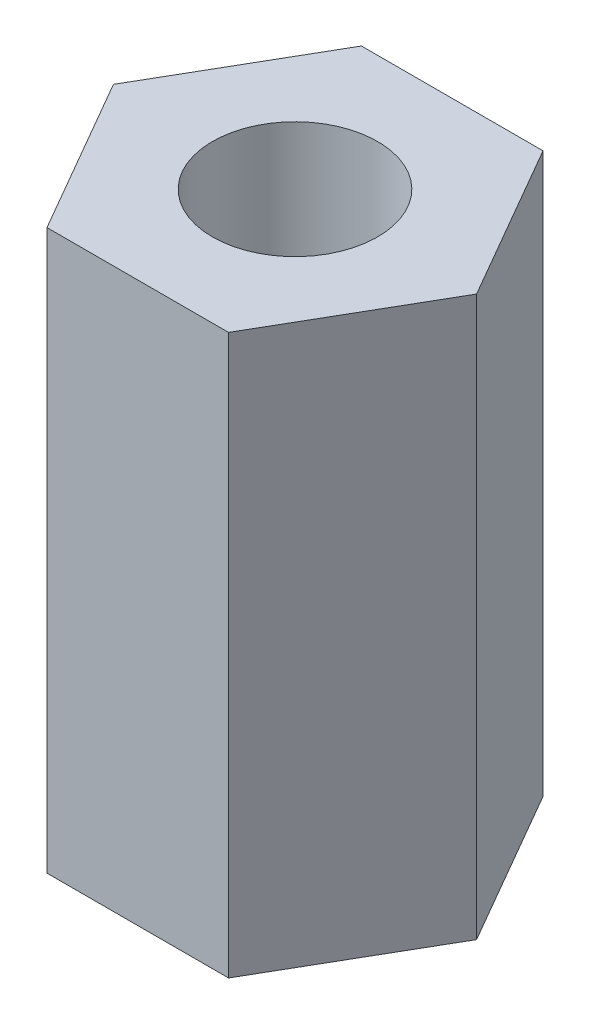
from build123d import *

# Parameters (mm, degrees)
SKETCH1_R           = 1.182555259
BOSS_EXTRUDE1_DEPTH = 8


with BuildPart() as part:
    # Sketch1 → Boss-Extrude1 (new body)
    with BuildSketch(Plane(origin=(0, 0, 0), x_dir=(1, 0, 0), z_dir=(0, 1, 0))):
        Polygon((2.598076211, 0), (1.299038106, 2.25), (-1.299038106, 2.25), (-2.598076211, 0), (-1.299038106, -2.25), (1.299038106, -2.25), align=None)
        Circle(SKETCH1_R, mode=Mode.SUBTRACT)
    extrude(amount=BOSS_EXTRUDE1_DEPTH)


solid = part.part
